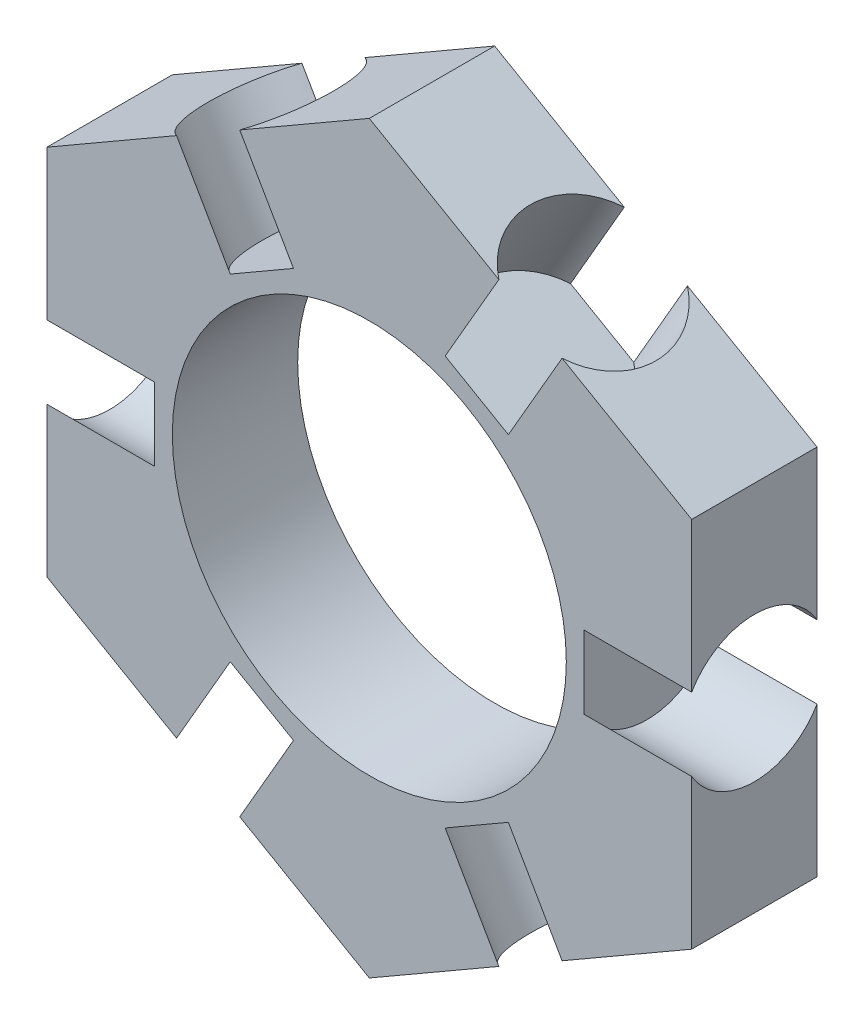
from build123d import *

# Parameters (mm, degrees)
SKETCH1_R           = 11
BOSS_EXTRUDE1_DEPTH = 3.5
SKETCH2_R           = 4.05
CUT_EXTRUDE3_DEPTH  = 6
CIRPATTERN1_COUNT   = 6


with BuildPart() as part:
    # Sketch1 → Boss-Extrude1 (new, symmetric)
    with BuildSketch(Plane.XY):
        Polygon((18, -10.392304845), (18, 10.392304845), (0, 20.784609691), (-18, 10.392304845), (-18, -10.392304845), (0, -20.784609691), align=None)
        Circle(SKETCH1_R, mode=Mode.SUBTRACT)
    extrude(amount=BOSS_EXTRUDE1_DEPTH, both=True)

    # Sketch2 → Cut-Extrude3 (cut)
    with BuildSketch(Plane(origin=(-12.610372246, -13.50400788, 0), x_dir=(0.8660254037844387, -0.49999999999999983, 0), z_dir=(0.49999999999999983, 0.8660254037844387, 0))):
        with Locations((4.168898776, 0)):
            Circle(SKETCH2_R)
    cut_extrude3 = extrude(amount=CUT_EXTRUDE3_DEPTH, mode=Mode.SUBTRACT)

    # CirPattern1: Cut-Extrude3 ×6 about axis
    cirpattern1_axis = Axis((0, 0, -3.5), (0, 0, 1))
    for i in range(1, CIRPATTERN1_COUNT):
        add(cut_extrude3.rotate(cirpattern1_axis, i * 360 / CIRPATTERN1_COUNT), mode=Mode.SUBTRACT)


solid = part.part
